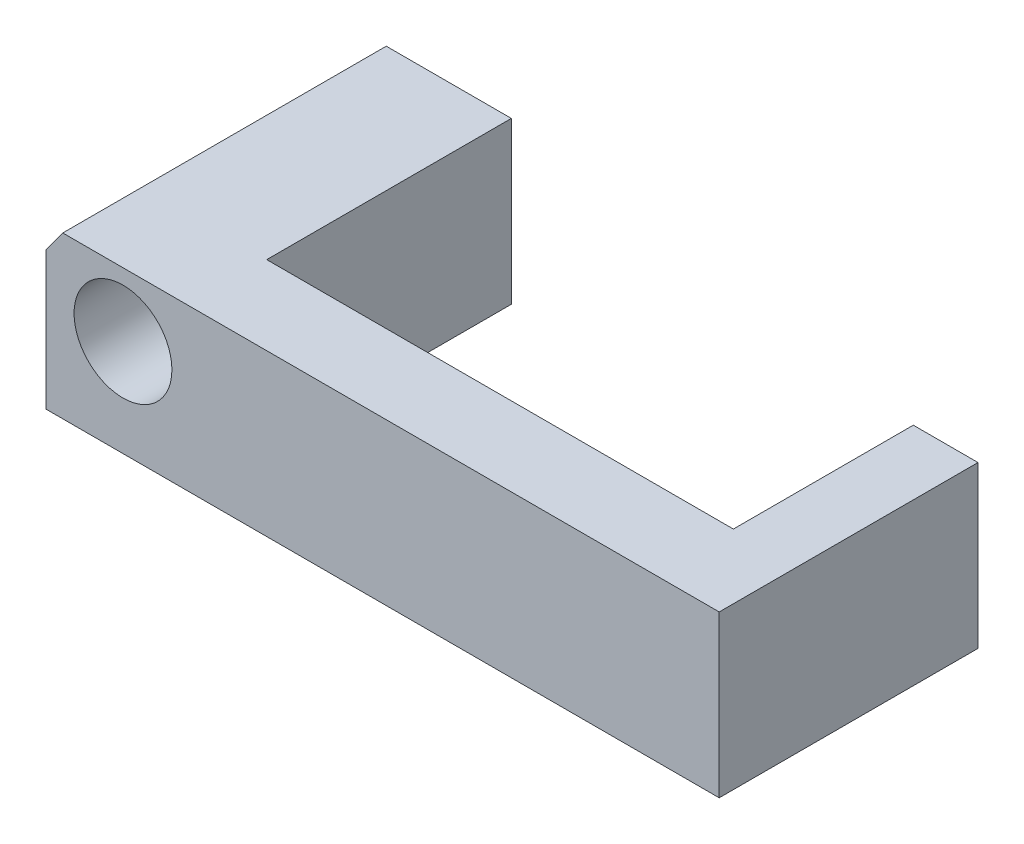
from build123d import *

# Parameters (mm, degrees)
BOSS_EXTRUDE1_DEPTH = 15.875
SKETCH2_W           = 3.87077
SKETCH2_H           = 7.9
BOSS_EXTRUDE2_DEPTH = 22.9
SKETCH3_W           = 3.175
SKETCH3_H           = 7.9
BOSS_EXTRUDE3_DEPTH = 12.7
SKETCH4_R           = 2.4003
CUT_EXTRUDE1_DEPTH  = 16.875


with BuildPart() as part:
    # Sketch1 → Boss-Extrude1 (new body)
    with BuildSketch(Plane.XY):
        Polygon((-96.811237268, -63.5), (-89.85, -63.5), (-89.85, -55.6), (-95.988636364, -55.6), (-96.811237268, -56.731076243), align=None)
    extrude(amount=BOSS_EXTRUDE1_DEPTH)

    # Sketch2 → Boss-Extrude2 (add)
    with BuildSketch(Plane(origin=(-89.85, 0, 0), x_dir=(0, 0, -1), z_dir=(1, 0, 0))):
        with Locations((-13.939615, -59.55)):
            Rectangle(SKETCH2_W, SKETCH2_H)
    extrude(amount=BOSS_EXTRUDE2_DEPTH)

    # Sketch3 → Boss-Extrude3 (add)
    with BuildSketch(Plane.XY.offset(15.875)):
        with Locations((-65.3625, -59.55)):
            Rectangle(SKETCH3_W, SKETCH3_H)
    extrude(amount=-BOSS_EXTRUDE3_DEPTH)

    # Sketch4 → Cut-Extrude1 (cut, through all)
    with BuildSketch(Plane.XY.offset(15.875)):
        with Locations((-93.032751555, -58.7375)):
            Circle(SKETCH4_R)
    extrude(amount=-CUT_EXTRUDE1_DEPTH, mode=Mode.SUBTRACT)


solid = part.part
